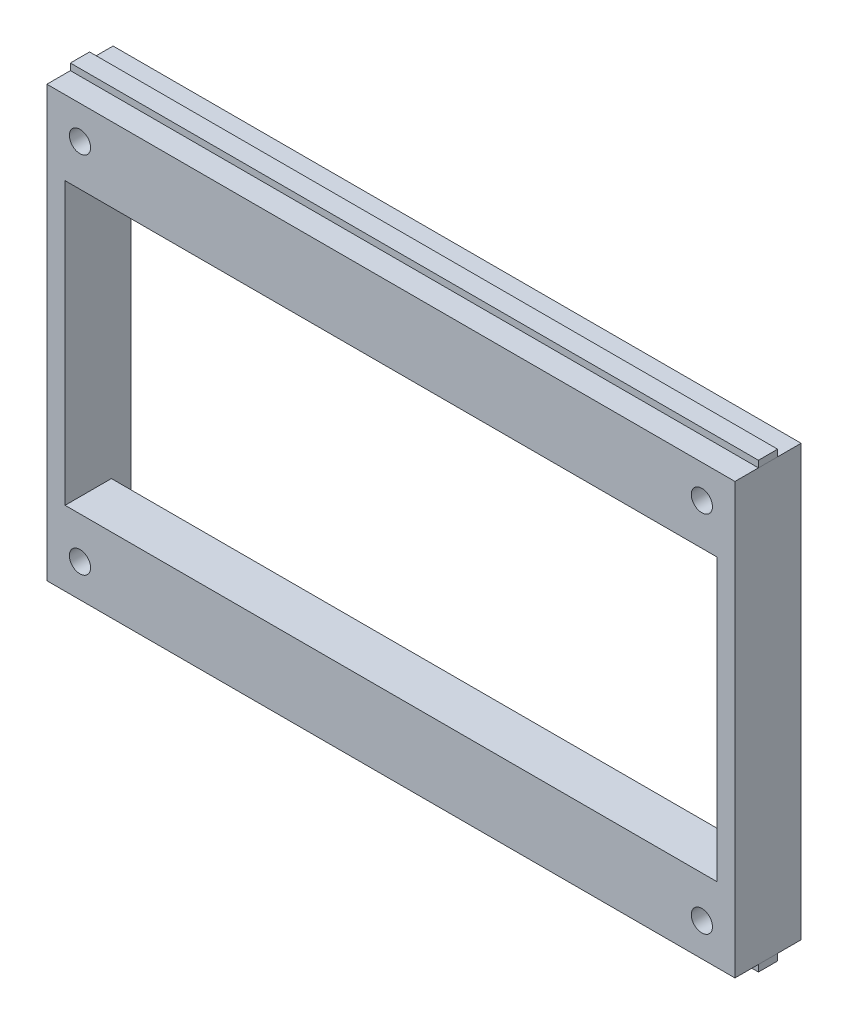
from build123d import *

# Parameters (mm, degrees)
MAIN_SKETCH_W                = 104
MAIN_SKETCH_H                = 65
MAIN_EXTRUSION_DEPTH         = 10
ESQUISSE2_W                  = 2.9
ESQUISSE2_H                  = 1
MAKERBEAM_ATTACHMENT_DEPTH   = 104
MAKERBEAM_ATTACHMENT_2_DEPTH = 104
ESQUISSE3_W                  = 98.5
ESQUISSE3_H                  = 42.5
HOLE_LCD_SCREEN_DEPTH        = 11
ESQUISSE4_R                  = 1.6
HOLES_SUPPORT_LCD_DEPTH      = 11
ESQUISSE5_W                  = 98.5
ESQUISSE5_H                  = 60
SUPPORTTOPANDBOTTOM_DEPTH    = 3
ESQUISSE6_W                  = 88
ESQUISSE6_H                  = 5
HOLES_FOR_PINS_DEPTH         = 3


with BuildPart() as part:
    # Main Sketch → Main Extrusion (new body)
    with BuildSketch(Plane.XY):
        Rectangle(MAIN_SKETCH_W, MAIN_SKETCH_H)
    extrude(amount=MAIN_EXTRUSION_DEPTH)

    # Esquisse3 → Hole LCD Screen (cut, through all)
    with BuildSketch(Plane.XY.offset(10)):
        Rectangle(ESQUISSE3_W, ESQUISSE3_H)
    extrude(amount=-HOLE_LCD_SCREEN_DEPTH, mode=Mode.SUBTRACT)

    # Esquisse4 → Holes Support LCD (cut, through all)
    with BuildSketch(Plane.XY.offset(10)):
        with Locations((-47, 27.5)):
            Circle(ESQUISSE4_R)
        with Locations((47, 27.5)):
            Circle(ESQUISSE4_R)
        with Locations((-47, -27.5)):
            Circle(ESQUISSE4_R)
        with Locations((47, -27.5)):
            Circle(ESQUISSE4_R)
    extrude(amount=-HOLES_SUPPORT_LCD_DEPTH, mode=Mode.SUBTRACT)

    # Esquisse5 → SupportTopAndBottom (cut)
    with BuildSketch(Plane(origin=(0, 0, 0), x_dir=(-1, 0, 0), z_dir=(0, 0, -1))):
        Rectangle(ESQUISSE5_W, ESQUISSE5_H)
    extrude(amount=-SUPPORTTOPANDBOTTOM_DEPTH, mode=Mode.SUBTRACT)

    # Esquisse6 → Holes For Pins (cut)
    with BuildSketch(Plane(origin=(0, 0, 3), x_dir=(-1, 0, 0), z_dir=(0, 0, -1))):
        with Locations((0, 27.5)):
            Rectangle(ESQUISSE6_W, ESQUISSE6_H)
        with Locations((0, -27.5)):
            Rectangle(ESQUISSE6_W, ESQUISSE6_H)
    extrude(amount=-HOLES_FOR_PINS_DEPTH, mode=Mode.SUBTRACT)


with BuildPart() as body_2:
    # Esquisse2 → MakerBeam Attachment (new body)
    with BuildSketch(Plane.ZY.offset(52)):
        with Locations((5, 33)):
            Rectangle(ESQUISSE2_W, ESQUISSE2_H)
    extrude(amount=-MAKERBEAM_ATTACHMENT_DEPTH)


with BuildPart() as body_3:
    # Esquisse2 → MakerBeam Attachment 2 (new body)
    with BuildSketch(Plane.ZY.offset(52)):
        with Locations((5, -33)):
            Rectangle(ESQUISSE2_W, ESQUISSE2_H)
    extrude(amount=-MAKERBEAM_ATTACHMENT_2_DEPTH)


solid = Compound([part.part, body_2.part, body_3.part])
